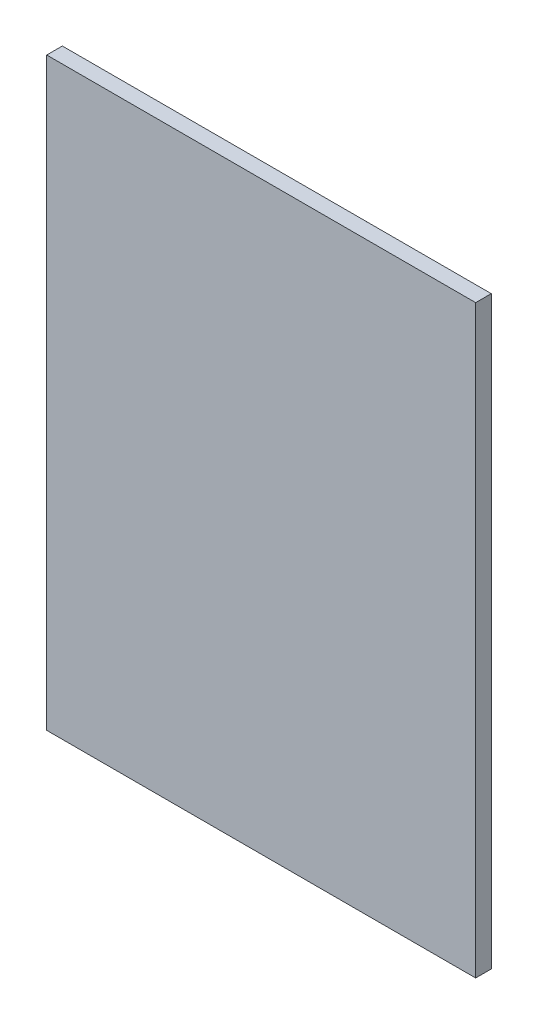
from build123d import *

# Parameters (mm, degrees)
SKETCH1_W           = 110
SKETCH1_H           = 150
BOSS_EXTRUDE1_DEPTH = 4


with BuildPart() as part:
    # Sketch1 → Boss-Extrude1 (new body)
    with BuildSketch(Plane.XY):
        with Locations((55, 75)):
            Rectangle(SKETCH1_W, SKETCH1_H)
    extrude(amount=BOSS_EXTRUDE1_DEPTH)


solid = part.part
